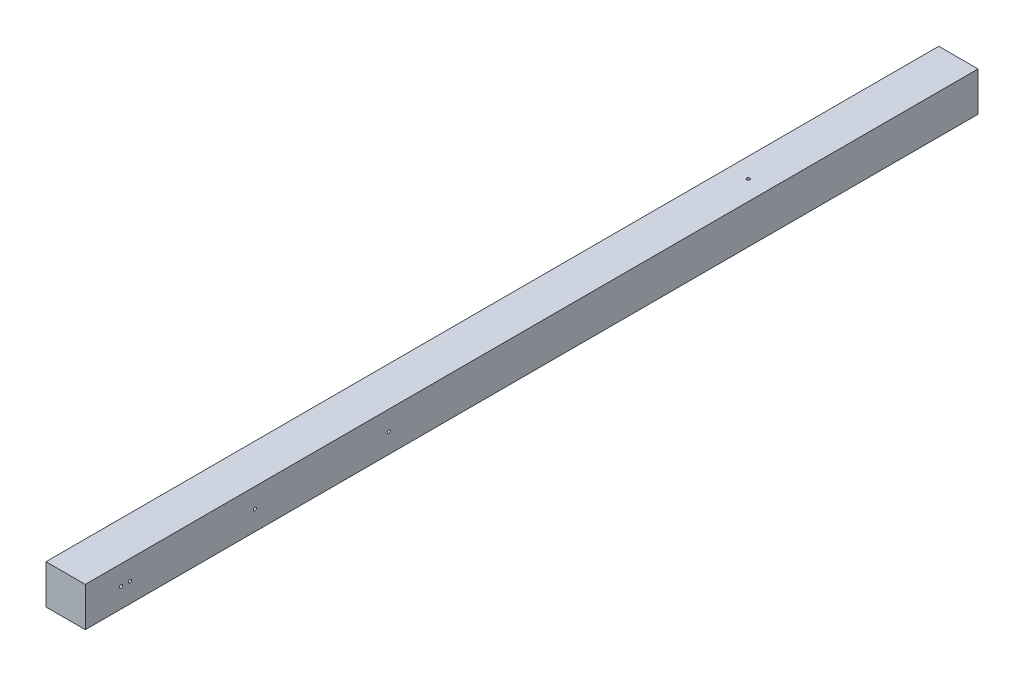
from build123d import *

# Parameters (mm, degrees)
ESQUISSE1_W             = 44
ESQUISSE1_H             = 44
BOSS_EXTRU_1_DEPTH      = 1000
ESQUISSE2_R             = 1.75
ENL_V_MAT_EXTRU_1_DEPTH = 44
ESQUISSE3_R             = 1.75
ENL_V_MAT_EXTRU_2_DEPTH = 44


with BuildPart() as part:
    # Esquisse1 → Boss.-Extru.1 (new body)
    with BuildSketch(Plane.XY):
        Rectangle(ESQUISSE1_W, ESQUISSE1_H)
    extrude(amount=BOSS_EXTRU_1_DEPTH)

    # Esquisse2 → Enlèv. mat.-Extru.1 (cut)
    with BuildSketch(Plane.ZY.offset(22)):
        with Locations((950, 0)):
            Circle(ESQUISSE2_R)
        with Locations((960, 0)):
            Circle(ESQUISSE2_R)
        with Locations((810, 0)):
            Circle(ESQUISSE2_R)
        with Locations((660, 0)):
            Circle(ESQUISSE2_R)
    extrude(amount=-ENL_V_MAT_EXTRU_1_DEPTH, mode=Mode.SUBTRACT)

    # Esquisse3 → Enlèv. mat.-Extru.2 (cut)
    with BuildSketch(Plane(origin=(0, 22, 0), x_dir=(1, 0, 0), z_dir=(0, 1, 0))):
        with Locations((0, -235.31)):
            Circle(ESQUISSE3_R)
    extrude(amount=-ENL_V_MAT_EXTRU_2_DEPTH, mode=Mode.SUBTRACT)


solid = part.part
